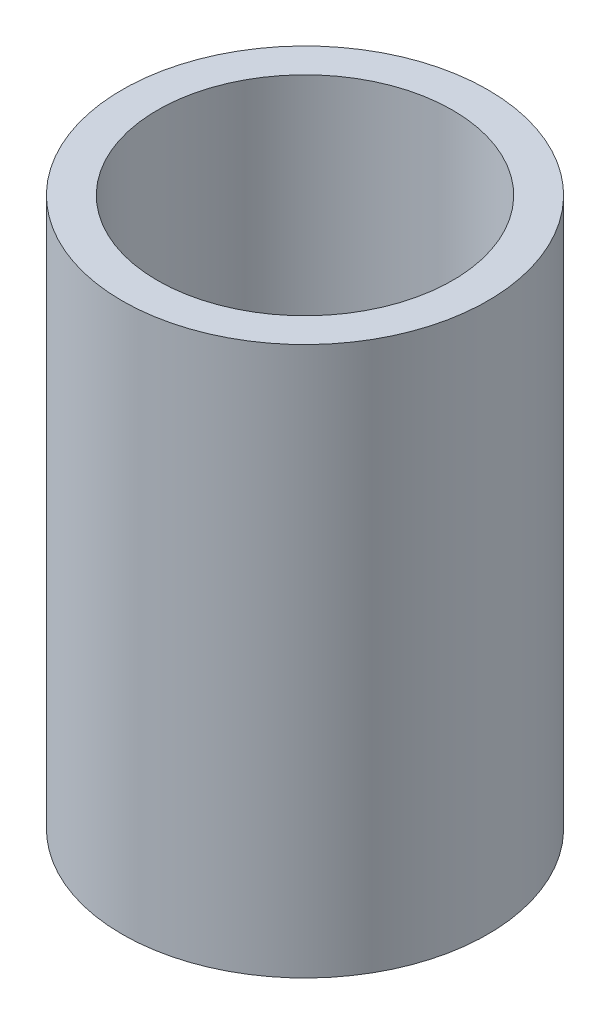
from build123d import *

# Parameters (mm, degrees)
SKETCH_1_W = 4.9
SKETCH_1_H = 76.2


with BuildPart() as part:
    # 草图1 → 旋转1 (revolve)
    with BuildSketch(Plane.XY, mode=Mode.PRIVATE) as revolve_1_sk:
        with Locations((22.95, 38.1)):
            Rectangle(SKETCH_1_W, SKETCH_1_H)
    revolve(revolve_1_sk.sketch.rotate(Axis((0, 161.376166943, 0), (0, -1, 0)), 90), axis=Axis((0, 161.376166943, 0), (0, -1, 0)))  # turned: the seam where the file's is


solid = part.part
